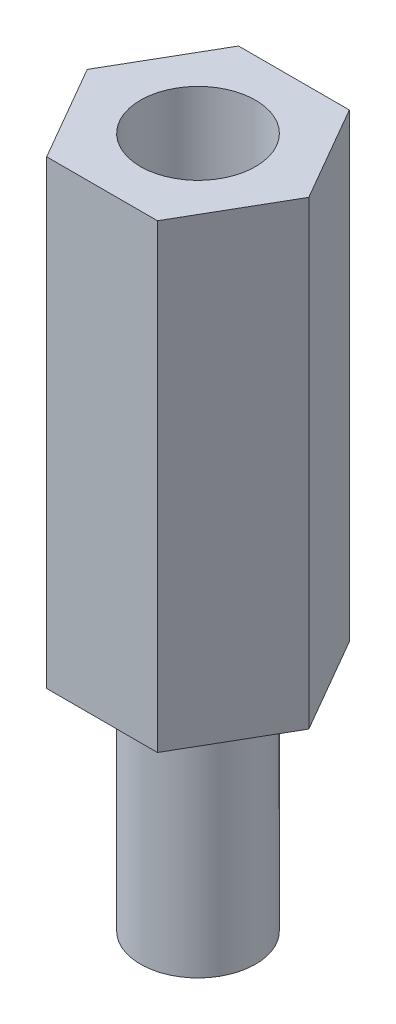
from build123d import *

# Parameters (mm, degrees)
CROQUIS1_R              = 1.5
SALIENTE_EXTRUIR1_DEPTH = 12
CROQUIS2_R              = 1.5
SALIENTE_EXTRUIR2_DEPTH = 6


with BuildPart() as part:
    # Croquis1 → Saliente-Extruir1 (new body)
    with BuildSketch(Plane(origin=(0, 0, 0), x_dir=(1, 0, 0), z_dir=(0, 1, 0))):
        Polygon((1.443375673, -2.5), (2.886751346, 0), (1.443375673, 2.5), (-1.443375673, 2.5), (-2.886751346, 0), (-1.443375673, -2.5), align=None)
        Circle(CROQUIS1_R, mode=Mode.SUBTRACT)
    extrude(amount=SALIENTE_EXTRUIR1_DEPTH)


with BuildPart() as body_2:
    # Croquis2 → Saliente-Extruir2 (new body)
    with BuildSketch(Plane.XZ):
        Circle(CROQUIS2_R)
    extrude(amount=SALIENTE_EXTRUIR2_DEPTH)


solid = Compound([part.part, body_2.part])
